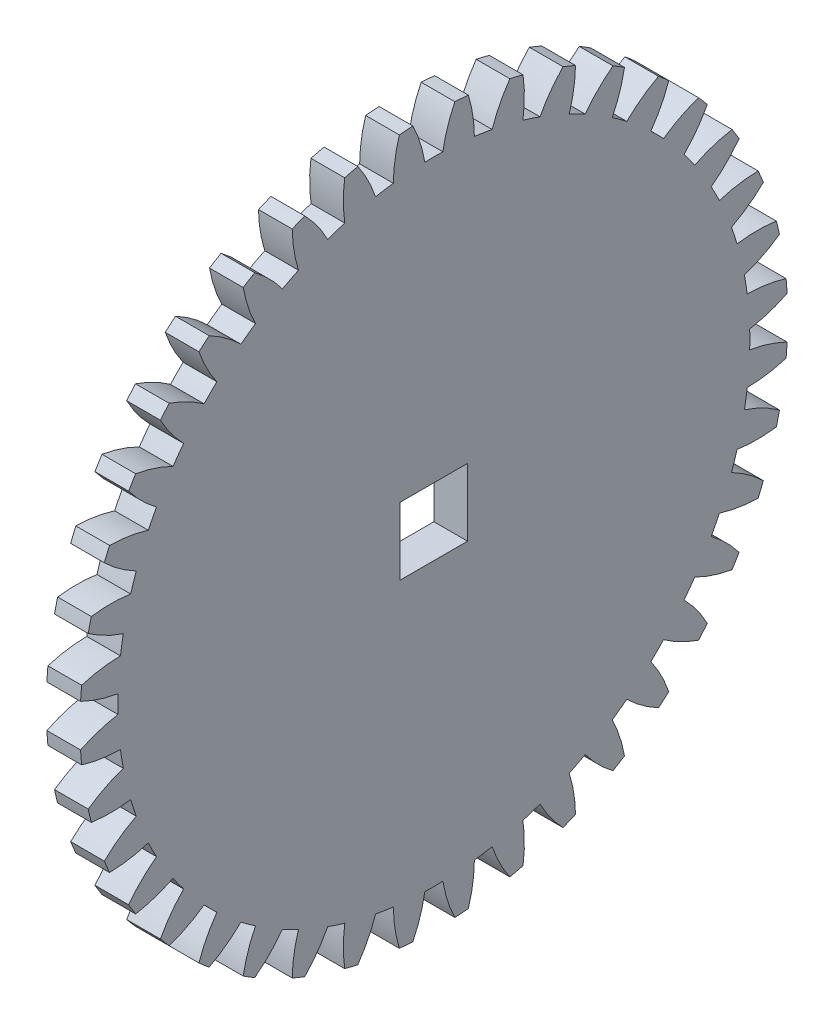
from build123d import *

# Parameters (mm, degrees)
BASPROSKE_W         = 4
BASPROSKE_H         = 42
TOOTHCUT_DEPTH      = 60.531504265
TEETHCUTS_COUNT     = 40
TEETHCUTS_ANGLE     = 351
SKETCH_1_W          = 8
SKETCH_1_H          = 8
CUT_EXTRUDE_1_DEPTH = 60.426818094


with BuildPart() as part:
    # BasProSke → Base-Revolve (revolve)
    with BuildSketch(Plane(origin=(0, 0, 0), x_dir=(1, 0, 0), z_dir=(0, 1, 0)), mode=Mode.PRIVATE) as base_revolve_sk:
        with Locations((2, 21)):
            Rectangle(BASPROSKE_W, BASPROSKE_H)
    revolve(base_revolve_sk.sketch.rotate(Axis((-10, 0, 0), (1, 0, 0)), 180), axis=Axis((-10, 0, 0), (1, 0, 0)))

    # TooCutSke → ToothCut (cut, through all)
    with BuildSketch(Plane(origin=(0, 0, 0), x_dir=(0, 0, -1), z_dir=(1, 0, 0))):
        with BuildLine():
            ThreePointArc((1.069221139, 37.483753376), (0, 37.499), (-1.069221139, 37.483753376))
            ThreePointArc((-1.069221139, 37.483753376), (-1.623716038, 39.770155553), (-2.507504748, 41.950526398))
            ThreePointArc((-2.507504748, 41.950526398), (0, 42.0254), (2.507504748, 41.950526398))
            ThreePointArc((2.507504748, 41.950526398), (1.623716038, 39.770155553), (1.069221139, 37.483753376))
        make_face()
    toothcut = extrude(amount=TOOTHCUT_DEPTH, mode=Mode.SUBTRACT)

    # TeethCuts: ToothCut ×40 about axis
    teethcuts_axis = Axis((-10, 0, 0), (1, 0, 0))
    for i in range(1, TEETHCUTS_COUNT):
        add(toothcut.rotate(teethcuts_axis, i * TEETHCUTS_ANGLE / (TEETHCUTS_COUNT - 1)), mode=Mode.SUBTRACT)

    # 草图1 → 切除-拉伸1 (cut, through all)
    with BuildSketch(Plane(origin=(4, 0, 0), x_dir=(0, 0, -1), z_dir=(1, 0, 0))):
        Rectangle(SKETCH_1_W, SKETCH_1_H)
    extrude(amount=-CUT_EXTRUDE_1_DEPTH, mode=Mode.SUBTRACT)


solid = part.part
